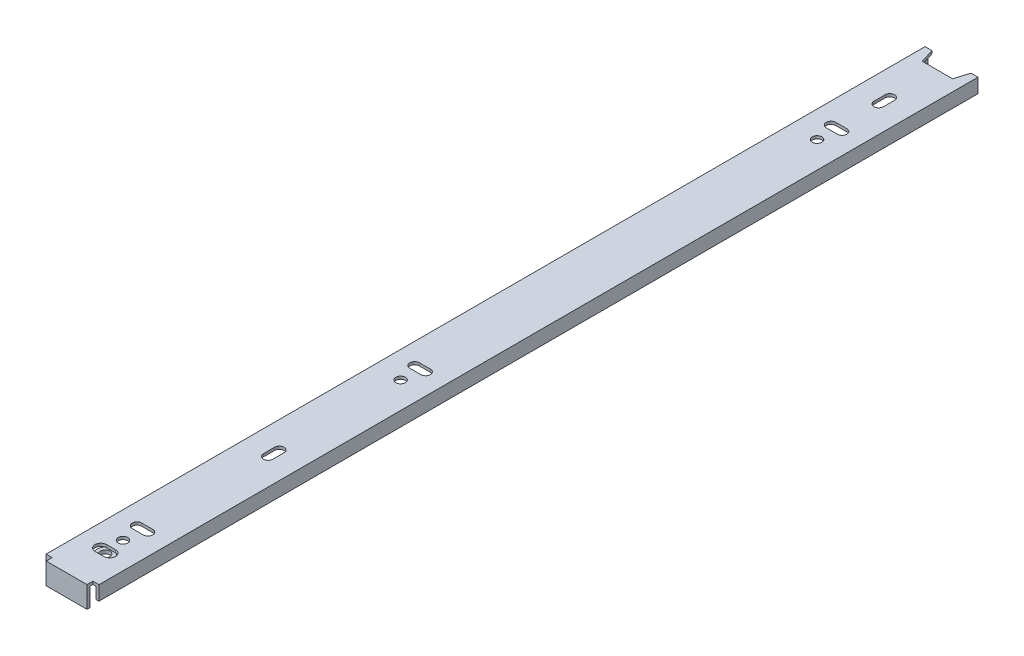
from build123d import *

# Parameters (mm, degrees)
BOSS_EXTRUDE1_DEPTH                              = 2.6
SKETCH2_W                                        = 24.4
SKETCH2_H                                        = 408
BOSS_EXTRUDE2_DEPTH                              = 1.3
SKETCH3_W                                        = 2.8
SKETCH3_H                                        = 2.7
CUT_EXTRUDE1_DEPTH                               = 4.9
SKETCH4_W                                        = 1.3
SKETCH4_H                                        = 405.3
BOSS_EXTRUDE3_DEPTH                              = 5.3
SKETCH5_W                                        = 2.8
SKETCH5_H                                        = 2.7
CUT_EXTRUDE2_DEPTH                               = 7.6
SKETCH6_W                                        = 1.3
SKETCH6_H                                        = 405.3
BOSS_EXTRUDE4_DEPTH                              = 5.3
SKETCH7_W                                        = 18.8
SKETCH7_H                                        = 1.4
BOSS_EXTRUDE5_DEPTH                              = 8.6
SKETCH8_W                                        = 14
SKETCH8_H                                        = 6.5
CUT_EXTRUDE3_DEPTH                               = 10.9
CUT_EXTRUDE4_DEPTH                               = 2.3
CUT_EXTRUDE5_DEPTH                               = 2.3
CUT_EXTRUDE6_DEPTH                               = 2.3
CUT_EXTRUDE7_DEPTH                               = 2.3
CUT_EXTRUDE8_DEPTH                               = 10.9
CUT_EXTRUDE9_DEPTH                               = 2.6
DRAFT1_ANGLE                                     = 17.102728969
F_4_4_4_4_DIAMETER_HOLE1_D                       = 4.4
F_4_4_4_4_DIAMETER_HOLE1_DEPTH                   = 1.3
CBORE_FOR_M4_HEX_HEAD_MACHINE_SCREW1_D           = 4.4
CBORE_FOR_M4_HEX_HEAD_MACHINE_SCREW1_DEPTH       = 3.9
CBORE_FOR_M4_HEX_HEAD_MACHINE_SCREW1_CBORE_D     = 7.5
CBORE_FOR_M4_HEX_HEAD_MACHINE_SCREW1_CBORE_DEPTH = 1
SCALE1_SCALE                                     = 0.25


with BuildPart() as part:
    # Sketch1 → Boss-Extrude1 (new body)
    with BuildSketch(Plane.XZ.offset(0.6)):
        with BuildLine():
            Line((3.75, 390.2), (3.140289704, 397.947144852))
            ThreePointArc((3.140289704, 397.947144852), (0, 400.85), (-3.140289704, 397.947144852))
            Line((-3.140289704, 397.947144852), (-3.75, 390.2))
            ThreePointArc((-3.75, 390.2), (0, 386.45), (3.75, 390.2))
        make_face()
    extrude(amount=-BOSS_EXTRUDE1_DEPTH)

    # Sketch2 → Boss-Extrude2 (add)
    with BuildSketch(Plane.XZ.offset(-2)):
        with Locations((0, 204)):
            Rectangle(SKETCH2_W, SKETCH2_H)
        with BuildLine():
            Line((-2.05, 392.9), (2.05, 392.9))
            ThreePointArc((2.05, 392.9), (4.75, 390.2), (2.05, 387.5))
            Line((2.05, 387.5), (-2.05, 387.5))
            ThreePointArc((-2.05, 387.5), (-4.75, 390.2), (-2.05, 392.9))
        make_face(mode=Mode.SUBTRACT)
    extrude(amount=-BOSS_EXTRUDE2_DEPTH)

    # Sketch3 → Cut-Extrude1 (cut, through all)
    with BuildSketch(Plane(origin=(0, 3.3, 0), x_dir=(-1, 0, 0), z_dir=(0, 1, 0))):
        with Locations((-10.8, 406.65)):
            Rectangle(SKETCH3_W, SKETCH3_H)
    extrude(amount=-CUT_EXTRUDE1_DEPTH, mode=Mode.SUBTRACT)

    # Sketch4 → Boss-Extrude3 (add)
    with BuildSketch(Plane.XZ.offset(-2)):
        with Locations((11.55, 202.65)):
            Rectangle(SKETCH4_W, SKETCH4_H)
    extrude(amount=BOSS_EXTRUDE3_DEPTH)

    # Sketch5 → Cut-Extrude2 (cut, through all)
    with BuildSketch(Plane(origin=(0, 3.3, 0), x_dir=(-1, 0, 0), z_dir=(0, 1, 0))):
        with Locations((10.8, 406.65)):
            Rectangle(SKETCH5_W, SKETCH5_H)
    extrude(amount=-CUT_EXTRUDE2_DEPTH, mode=Mode.SUBTRACT)

    # Sketch6 → Boss-Extrude4 (add)
    with BuildSketch(Plane.XZ.offset(-2)):
        with Locations((-11.55, 202.65)):
            Rectangle(SKETCH6_W, SKETCH6_H)
    extrude(amount=BOSS_EXTRUDE4_DEPTH)

    # Sketch7 → Boss-Extrude5 (add)
    with BuildSketch(Plane.XZ.offset(-2)):
        with Locations((0, 407.3)):
            Rectangle(SKETCH7_W, SKETCH7_H)
    extrude(amount=BOSS_EXTRUDE5_DEPTH)

    # Sketch8 → Cut-Extrude3 (cut, through all)
    with BuildSketch(Plane(origin=(0, 3.3, 0), x_dir=(-1, 0, 0), z_dir=(0, 1, 0))):
        with Locations((0, 3.25)):
            Rectangle(SKETCH8_W, SKETCH8_H)
    extrude(amount=-CUT_EXTRUDE3_DEPTH, mode=Mode.SUBTRACT)

    # Sketch9 → Cut-Extrude4 (cut, through all)
    with BuildSketch(Plane.XZ.offset(-2)):
        with BuildLine():
            Line((2.55, 375.200000014), (-2.55, 375.200000014))
            ThreePointArc((-2.55, 375.200000014), (-4.75, 373.000000014), (-2.55, 370.800000014))
            Line((-2.55, 370.800000014), (2.55, 370.800000014))
            ThreePointArc((2.55, 370.800000014), (4.75, 373.000000014), (2.55, 375.200000014))
        make_face()
    extrude(amount=-CUT_EXTRUDE4_DEPTH, mode=Mode.SUBTRACT)

    # Sketch10 → Cut-Extrude5 (cut, through all)
    with BuildSketch(Plane.XZ.offset(-2)):
        with BuildLine():
            Line((-2.549860329, 242.799983225), (2.550139671, 242.8))
            ThreePointArc((2.550139671, 242.8), (4.750132435, 245.000007236), (2.550125198, 247.2))
            Line((2.550125198, 247.2), (-2.549874802, 247.199983225))
            ThreePointArc((-2.549874802, 247.199983225), (-4.749867565, 244.999975989), (-2.549860329, 242.799983225))
        make_face()
    extrude(amount=-CUT_EXTRUDE5_DEPTH, mode=Mode.SUBTRACT)

    # Sketch11 → Cut-Extrude6 (cut, through all)
    with BuildSketch(Plane.XZ.offset(-2)):
        with BuildLine():
            Line((2.200125198, 309.95), (2.200125198, 315.05))
            ThreePointArc((2.200125198, 315.05), (0.000125198, 317.25), (-2.199874802, 315.05))
            Line((-2.199874802, 315.05), (-2.199874802, 309.95))
            ThreePointArc((-2.199874802, 309.95), (0.000125198, 307.75), (2.200125198, 309.95))
        make_face()
    extrude(amount=-CUT_EXTRUDE6_DEPTH, mode=Mode.SUBTRACT)

    # Sketch12 → Cut-Extrude7 (cut, through all)
    with BuildSketch(Plane.XZ.offset(-2)):
        with BuildLine():
            Line((2.200125198, 28.45), (2.200125198, 33.55))
            ThreePointArc((2.200125198, 33.55), (0.000125198, 35.75), (-2.199874802, 33.55))
            Line((-2.199874802, 33.55), (-2.199874802, 28.45))
            ThreePointArc((-2.199874802, 28.45), (0.000125198, 26.25), (2.200125198, 28.45))
        make_face()
    extrude(amount=-CUT_EXTRUDE7_DEPTH, mode=Mode.SUBTRACT)

    # Sketch13 → Cut-Extrude8 (cut, through all)
    with BuildSketch(Plane(origin=(0, 3.3, 0), x_dir=(-1, 0, 0), z_dir=(0, 1, 0))):
        with BuildLine():
            Line((2.549874802, 55.2), (-2.550125198, 55.2))
            ThreePointArc((-2.550125198, 55.2), (-4.750125198, 53), (-2.550125198, 50.8))
            Line((-2.550125198, 50.8), (2.549874802, 50.8))
            ThreePointArc((2.549874802, 50.8), (4.749874802, 53), (2.549874802, 55.2))
        make_face()
    extrude(amount=-CUT_EXTRUDE8_DEPTH, mode=Mode.SUBTRACT)

    # Sketch14 → Cut-Extrude9 (cut)
    with BuildSketch(Plane.XZ.offset(0.6)):
        Polygon((0.6, 397.1), (2.2, 397.1), (2.2, 398.3), (0.6, 398.3), (0.6, 399.9), (-0.6, 399.9), (-0.6, 398.3), (-2.2, 398.3), (-2.2, 397.1), (-0.6, 397.1), (-0.6, 395.5), (0.6, 395.5), align=None)
    extrude(amount=-CUT_EXTRUDE9_DEPTH, mode=Mode.SUBTRACT)

    # Draft1
    draft1_faces = [part.faces().sort_by_distance(p)[0] for p in [
        (-7, 2.65, 3.25),
        (7, 2.65, 3.25),
    ]]
    draft(draft1_faces, Plane(origin=(-7, -6.6, 6.5), x_dir=(0, -1, 0), z_dir=(0, 0, -1)), DRAFT1_ANGLE)

    # Ø4.4 (4.4) Diameter Hole1
    with Locations(Plane(origin=(0, 2, 0), x_dir=(-1, 0, 0), z_dir=(0, -1, 0))):
        with Locations((-0.000125198, -62), (-0.000125198, -254), (0, -382)):
            Hole(F_4_4_4_4_DIAMETER_HOLE1_D / 2, depth=F_4_4_4_4_DIAMETER_HOLE1_DEPTH)

    # CBORE for M4 Hex Head Machine Screw1
    with Locations(Plane(origin=(0, -0.6, 0), x_dir=(-1, 0, 0), z_dir=(0, -1, 0))):
        with Locations((0, -390.2)):
            CounterBoreHole(CBORE_FOR_M4_HEX_HEAD_MACHINE_SCREW1_D / 2, CBORE_FOR_M4_HEX_HEAD_MACHINE_SCREW1_CBORE_D / 2, CBORE_FOR_M4_HEX_HEAD_MACHINE_SCREW1_CBORE_DEPTH, depth=CBORE_FOR_M4_HEX_HEAD_MACHINE_SCREW1_DEPTH)


with BuildPart() as part_1:
    # Scale1: scaled about (-1.622e-06, 1.572421019, 208.139009322)
    add(part.part.scale(SCALE1_SCALE).moved(Location((-1.217e-06, 1.179315764, 156.104256991))))


solid = part_1.part
